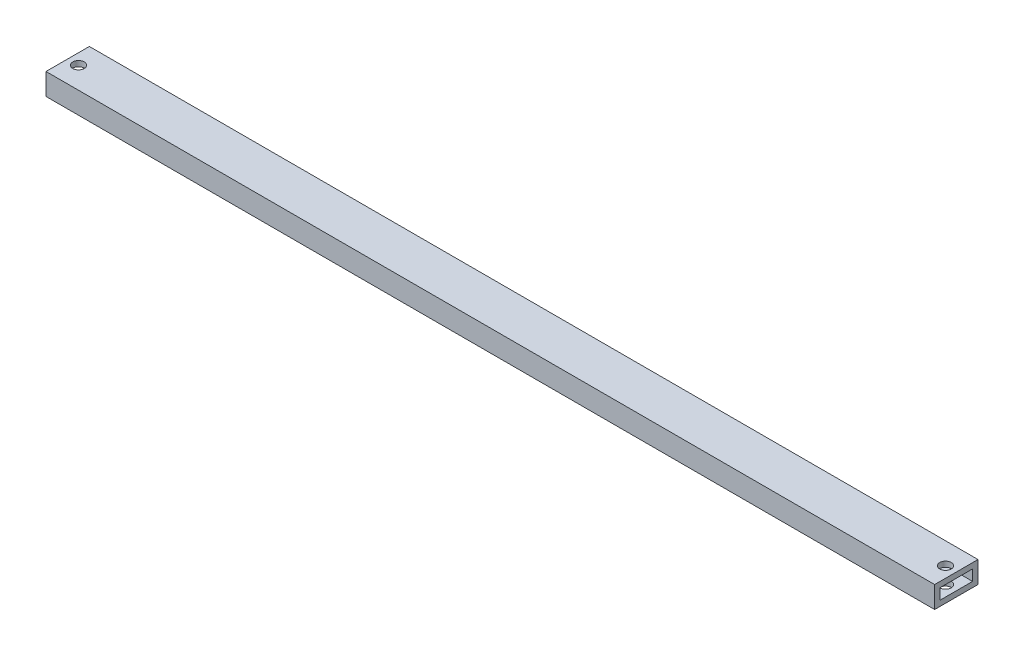
from build123d import *

# Parameters (mm, degrees)
SKETCH1_W           = 25.4
SKETCH1_H           = 12.7
SKETCH1_W_2         = 19.05
SKETCH1_H_2         = 6.35
BOSS_EXTRUDE1_DEPTH = 520.7
SKETCH2_R           = 3.3528
CUT_EXTRUDE1_DEPTH  = 13.7


with BuildPart() as part:
    # Sketch1 → Boss-Extrude1 (new body)
    with BuildSketch(Plane(origin=(0, 0, 0), x_dir=(0, 0, -1), z_dir=(1, 0, 0))):
        with Locations((12.7, 6.35)):
            Rectangle(SKETCH1_W, SKETCH1_H)
        with Locations((12.7, 6.35)):
            Rectangle(SKETCH1_W_2, SKETCH1_H_2, mode=Mode.SUBTRACT)
    extrude(amount=BOSS_EXTRUDE1_DEPTH)

    # Sketch2 → Cut-Extrude1 (cut, through all)
    with BuildSketch(Plane(origin=(0, 12.7, 0), x_dir=(1, 0, 0), z_dir=(0, 1, 0))):
        with Locations((6.35, 12.7)):
            Circle(SKETCH2_R)
        with Locations((514.35, 12.7)):
            Circle(SKETCH2_R)
    extrude(amount=-CUT_EXTRUDE1_DEPTH, mode=Mode.SUBTRACT)


solid = part.part
